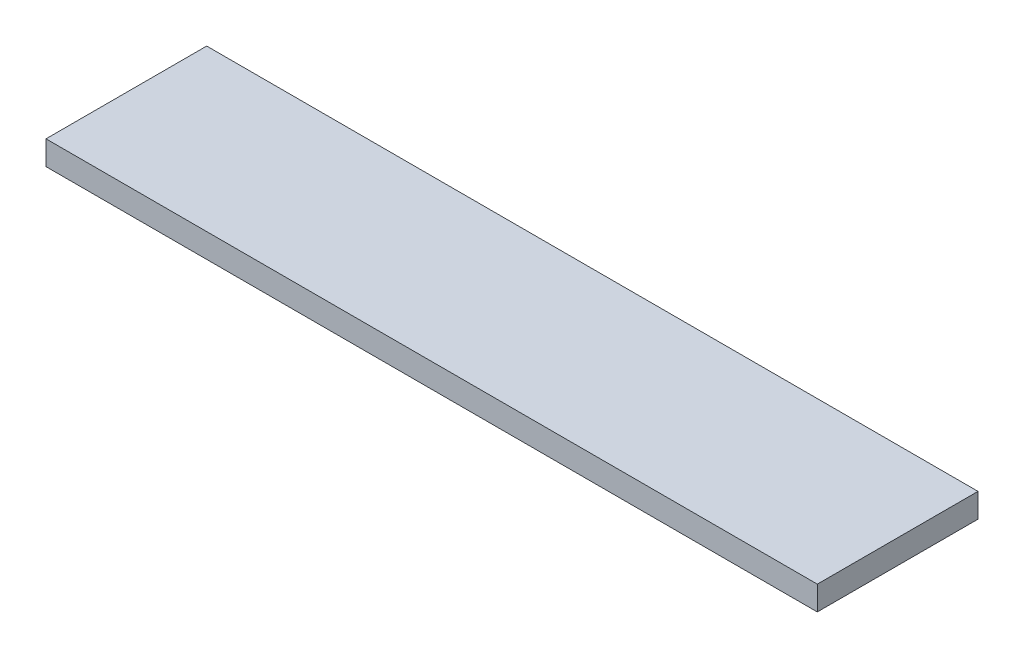
from build123d import *

# Parameters (mm, degrees)
SKIZZE1_W                       = 192
SKIZZE1_H                       = 40
AUFSATZ_LINEAR_AUSTRAGEN1_DEPTH = 6


with BuildPart() as part:
    # Skizze1 → Aufsatz-Linear austragen1 (new body)
    with BuildSketch(Plane(origin=(0, 0, 0), x_dir=(1, 0, 0), z_dir=(0, 1, 0))):
        with Locations((96, 20)):
            Rectangle(SKIZZE1_W, SKIZZE1_H)
    extrude(amount=AUFSATZ_LINEAR_AUSTRAGEN1_DEPTH)


solid = part.part
